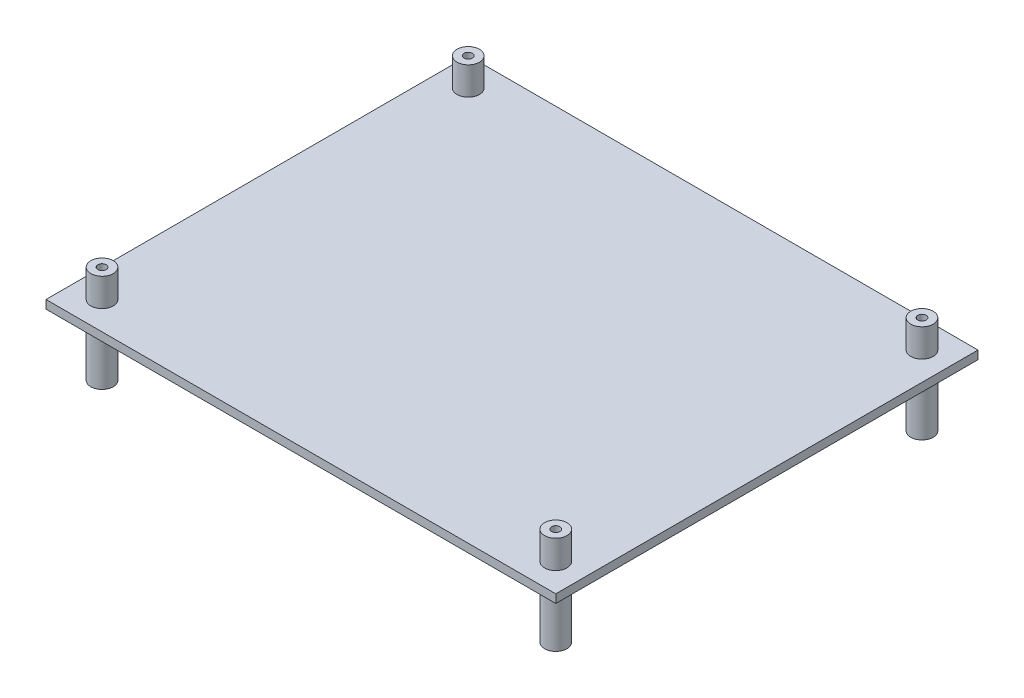
from build123d import *

# Parameters (mm, degrees)
SKETCH1_W                = 182
SKETCH1_H                = 150.75023901
SKETCH1_R                = 1.5
BOSS_EXTRUDE1_DEPTH      = 3
SKETCH2_R                = 4
SKETCH2_R_2              = 1.5
BOSS_EXTRUDE2_DEPTH      = 10
BOSS_EXTRUDE2_DEPTH_BACK = 25


with BuildPart() as part:
    # Sketch1 → Boss-Extrude1 (new body)
    with BuildSketch(Plane(origin=(0, 0, 0), x_dir=(1, 0, 0), z_dir=(0, 1, 0))):
        with Locations((81, 65.375119505)):
            Rectangle(SKETCH1_W, SKETCH1_H)
        with Locations((0, 130.75023901)):
            Circle(SKETCH1_R, mode=Mode.SUBTRACT)
        with Locations((162, 130.75023901)):
            Circle(SKETCH1_R, mode=Mode.SUBTRACT)
        with Locations((162, 0)):
            Circle(SKETCH1_R, mode=Mode.SUBTRACT)
        Circle(SKETCH1_R, mode=Mode.SUBTRACT)
    extrude(amount=BOSS_EXTRUDE1_DEPTH)

    # Sketch2 → Boss-Extrude2 (add, two sides)
    with BuildSketch(Plane(origin=(0, 3, 0), x_dir=(1, 0, 0), z_dir=(0, 1, 0))) as boss_extrude2_sk:
        with Locations((0, 130.75023901)):
            Circle(SKETCH2_R)
        with Locations((0, 130.75023901)):
            Circle(SKETCH2_R_2, mode=Mode.SUBTRACT)
        with Locations((162, 130.75023901)):
            Circle(SKETCH2_R)
        with Locations((162, 130.75023901)):
            Circle(SKETCH2_R_2, mode=Mode.SUBTRACT)
        with Locations((162, 0)):
            Circle(SKETCH2_R)
        with Locations((162, 0)):
            Circle(SKETCH2_R_2, mode=Mode.SUBTRACT)
        Circle(SKETCH2_R)
        Circle(SKETCH2_R_2, mode=Mode.SUBTRACT)
    extrude(amount=BOSS_EXTRUDE2_DEPTH)
    extrude(boss_extrude2_sk.sketch, amount=-BOSS_EXTRUDE2_DEPTH_BACK)


solid = part.part
